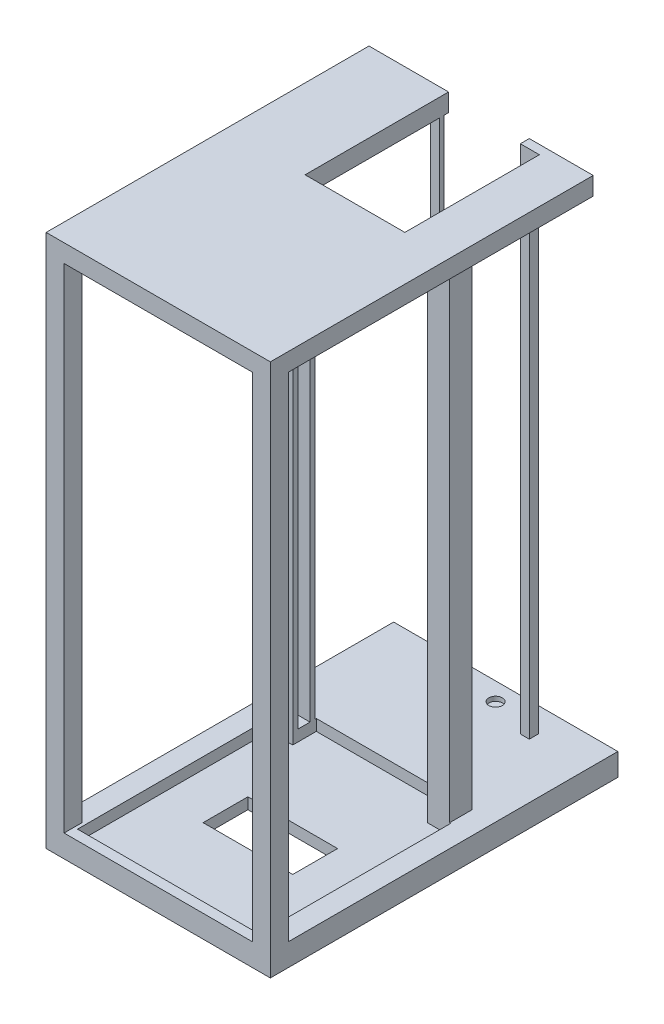
from build123d import *

# Parameters (mm, degrees)
SKETCH1_W           = 100
SKETCH1_H           = 100
BOSS_EXTRUDE1_DEPTH = 10
BOSS_EXTRUDE2_DEPTH = 220
SKETCH4_W           = 100
SKETCH4_H           = 40
BOSS_EXTRUDE3_DEPTH = 10
SKETCH5_W           = 100
SKETCH5_H           = 140
BOSS_EXTRUDE4_DEPTH = 8
CUT_EXTRUDE2_DEPTH  = 11
SKETCH7_W           = 8
SKETCH7_H           = 8
BOSS_EXTRUDE5_DEPTH = 220
CUT_EXTRUDE3_DEPTH  = 5
CUT_EXTRUDE4_REACH  = 7
SKETCH9_W           = 40
SKETCH9_H           = 20
SKETCH11_W          = 100
SKETCH11_H          = 15
BOSS_EXTRUDE6_DEPTH = 10
SKETCH12_R          = 3
CUT_EXTRUDE5_DEPTH  = 2
BOSS_EXTRUDE7_DEPTH = 228
SKETCH14_W          = 35.5
SKETCH14_H          = 4
SKETCH14_W_2        = 28.5
BOSS_EXTRUDE8_DEPTH = 8


with BuildPart() as part:
    # Sketch1 → Boss-Extrude1 (new body)
    with BuildSketch(Plane(origin=(0, 0, 0), x_dir=(1, 0, 0), z_dir=(0, 1, 0))):
        Rectangle(SKETCH1_W, SKETCH1_H)
    extrude(amount=BOSS_EXTRUDE1_DEPTH)

    # Sketch3 → Boss-Extrude2 (add)
    with BuildSketch(Plane(origin=(0, 10, 0), x_dir=(1, 0, 0), z_dir=(0, 1, 0))):
        Polygon((-40, 40), (-40, 50), (-30, 50), (-30, 47.7), (-37, 47.7), (-37, 42.3), (-30, 42.3), (-30, 40), align=None)
        Polygon((30, 42.3), (30, 40), (40, 40), (40, 50), (30, 50), (30, 47.7), (37, 47.7), (37, 42.3), align=None)
    extrude(amount=BOSS_EXTRUDE2_DEPTH)

    # Sketch4 → Boss-Extrude3 (add)
    with BuildSketch(Plane(origin=(0, 0, 0), x_dir=(1, 0, 0), z_dir=(0, 1, 0))):
        with Locations((0, 70)):
            Rectangle(SKETCH4_W, SKETCH4_H)
    extrude(amount=BOSS_EXTRUDE3_DEPTH)

    # Sketch5 → Boss-Extrude4 (add)
    with BuildSketch(Plane(origin=(0, 230, 0), x_dir=(1, 0, 0), z_dir=(0, 1, 0))):
        with Locations((0, 20)):
            Rectangle(SKETCH5_W, SKETCH5_H)
    extrude(amount=BOSS_EXTRUDE4_DEPTH)

    # Sketch6 → Cut-Extrude2 (cut)
    with BuildSketch(Plane(origin=(0, 238, 0), x_dir=(1, 0, 0), z_dir=(0, 1, 0))):
        Polygon((-4.5, 30), (30, 30), (30, 90), (-4.5, 90), (-14.5, 90), (-14.5, 30), align=None)
    extrude(amount=-CUT_EXTRUDE2_DEPTH, mode=Mode.SUBTRACT)

    # Sketch7 → Boss-Extrude5 (add)
    with BuildSketch(Plane(origin=(0, 10, 0), x_dir=(1, 0, 0), z_dir=(0, 1, 0))):
        with Locations((-46, -46)):
            Rectangle(SKETCH7_W, SKETCH7_H)
        with Locations((46, -46)):
            Rectangle(SKETCH7_W, SKETCH7_H)
    extrude(amount=BOSS_EXTRUDE5_DEPTH)

    # Sketch8 → Cut-Extrude3 (cut)
    with BuildSketch(Plane(origin=(0, 10, 0), x_dir=(1, 0, 0), z_dir=(0, 1, 0))):
        Polygon((30, 40), (40.5, 40), (40.5, -45.5), (-40.5, -45.5), (-40.5, 40), (-30, 40), (-30, 50.5), (30, 50.5), align=None)
    extrude(amount=-CUT_EXTRUDE3_DEPTH, mode=Mode.SUBTRACT)

    # Sketch9 → Cut-Extrude4 (cut, up to next)
    with BuildSketch(Plane(origin=(0, 5, 0), x_dir=(1, 0, 0), z_dir=(0, 1, 0)), mode=Mode.PRIVATE) as cut_extrude4_sk1:
        Rectangle(SKETCH9_W, SKETCH9_H)
    cut_extrude4_tool1 = extrude(cut_extrude4_sk1.sketch, amount=-CUT_EXTRUDE4_REACH, mode=Mode.PRIVATE) & part.part
    add(cut_extrude4_tool1.solids().sort_by_distance((0, 5, 0))[0], mode=Mode.SUBTRACT)

    # Sketch11 → Boss-Extrude6 (add)
    with BuildSketch(Plane(origin=(0, 0, 0), x_dir=(1, 0, 0), z_dir=(0, 1, 0))):
        with Locations((0, 97.5)):
            Rectangle(SKETCH11_W, SKETCH11_H)
    extrude(amount=BOSS_EXTRUDE6_DEPTH)

    # Sketch12 → Cut-Extrude5 (cut)
    with BuildSketch(Plane(origin=(0, 10, 0), x_dir=(1, 0, 0), z_dir=(0, 1, 0))):
        with Locations((3.5, 96.967812545)):
            Circle(SKETCH12_R)
    extrude(amount=-CUT_EXTRUDE5_DEPTH, mode=Mode.SUBTRACT)

    # Sketch13 → Boss-Extrude7 (add)
    with BuildSketch(Plane(origin=(0, 10, 0), x_dir=(1, 0, 0), z_dir=(0, 1, 0))):
        Polygon((21.5, 92), (23.5, 92), (23.5, 94), (25.5, 94), (25.5, 90), (21.5, 90), align=None)
        Polygon((-14.5, 92), (-16.5, 92), (-16.5, 94), (-18.5, 94), (-18.5, 90), (-14.5, 90), align=None)
    extrude(amount=BOSS_EXTRUDE7_DEPTH)

    # Sketch14 → Boss-Extrude8 (add)
    with BuildSketch(Plane(origin=(0, 238, 0), x_dir=(1, 0, 0), z_dir=(0, 1, 0))):
        with Locations((-32.25, 92)):
            Rectangle(SKETCH14_W, SKETCH14_H)
        with Locations((35.75, 92)):
            Rectangle(SKETCH14_W_2, SKETCH14_H)
    extrude(amount=-BOSS_EXTRUDE8_DEPTH)


solid = part.part
